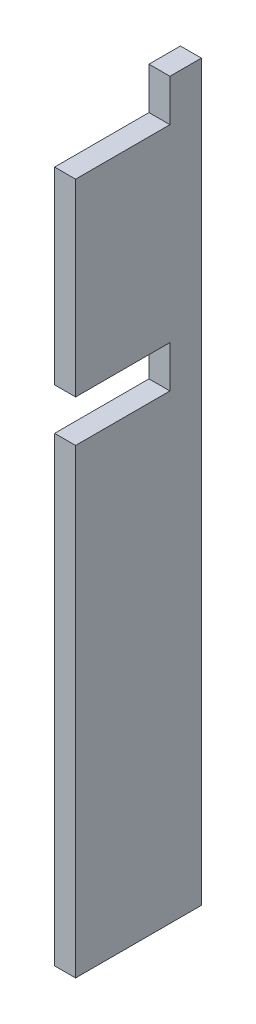
from build123d import *

# Parameters (mm, degrees)
SKETCH1_W           = 19.05
SKETCH1_H           = 111.125
BOSS_EXTRUDE1_DEPTH = 1.5875
SKETCH2_W           = 14.2875
SKETCH2_H           = 6.35
CUT_EXTRUDE1_DEPTH  = 4.175


with BuildPart() as part:
    # Sketch1 → Boss-Extrude1 (new body, symmetric)
    with BuildSketch(Plane(origin=(0, 0, 0), x_dir=(0, 0, -1), z_dir=(1, 0, 0))):
        Rectangle(SKETCH1_W, SKETCH1_H)
    extrude(amount=BOSS_EXTRUDE1_DEPTH, both=True)

    # Sketch2 → Cut-Extrude1 (cut, through all)
    with BuildSketch(Plane(origin=(1.5875, 0, 0), x_dir=(0, 0, -1), z_dir=(1, 0, 0))):
        with Locations((-2.38125, 52.3875)):
            Rectangle(SKETCH2_W, SKETCH2_H)
        with Locations((-2.38125, 17.4625)):
            Rectangle(SKETCH2_W, SKETCH2_H)
    extrude(amount=-CUT_EXTRUDE1_DEPTH, mode=Mode.SUBTRACT)


solid = part.part
